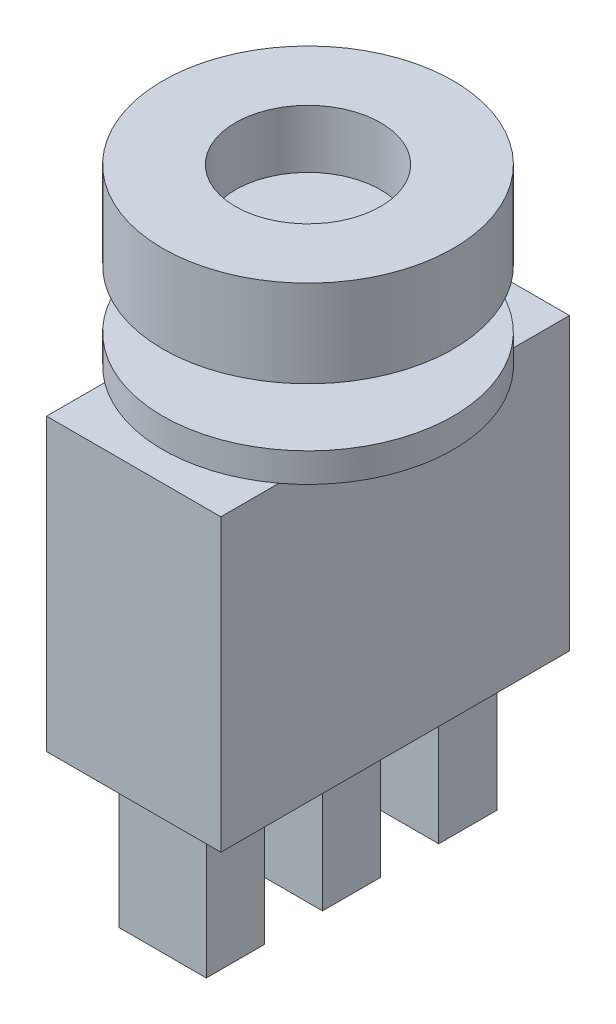
from build123d import *

# Parameters (mm, degrees)
ESQUISSE1_R      = 5
EXTRUSION1_DEPTH = 3
ESQUISSE3_R      = 2
EXTRUSION3_DEPTH = 2
ESQUISSE4_R      = 5
EXTRUSION4_DEPTH = 1
ESQUISSE5_W      = 6
ESQUISSE5_H      = 12
EXTRUSION5_DEPTH = 10
ESQUISSE6_W      = 3
ESQUISSE6_H      = 2
EXTRUSION6_DEPTH = 5
ESQUISSE2_R      = 2.5
EXTRUSION7_DEPTH = 2


with BuildPart() as part:
    # Esquisse1 → Extrusion1 (new body)
    with BuildSketch(Plane(origin=(0, 0, 0), x_dir=(1, 0, 0), z_dir=(0, 1, 0))):
        Circle(ESQUISSE1_R)
    extrude(amount=EXTRUSION1_DEPTH)

    # Esquisse3 → Extrusion3 (add)
    with BuildSketch(Plane.XZ):
        Circle(ESQUISSE3_R)
    extrude(amount=EXTRUSION3_DEPTH)

    # Esquisse4 → Extrusion4 (add)
    with BuildSketch(Plane.XZ.offset(2)):
        Circle(ESQUISSE4_R)
    extrude(amount=EXTRUSION4_DEPTH)

    # Esquisse5 → Extrusion5 (add)
    with BuildSketch(Plane.XZ.offset(3)):
        Rectangle(ESQUISSE5_W, ESQUISSE5_H)
    extrude(amount=EXTRUSION5_DEPTH)

    # Esquisse6 → Extrusion6 (add)
    with BuildSketch(Plane.XZ.offset(13)):
        with Locations((0, 4)):
            Rectangle(ESQUISSE6_W, ESQUISSE6_H)
        Rectangle(ESQUISSE6_W, ESQUISSE6_H)
        with Locations((0, -4)):
            Rectangle(ESQUISSE6_W, ESQUISSE6_H)
    extrude(amount=EXTRUSION6_DEPTH)

    # Esquisse2 → Extrusion7 (cut)
    with BuildSketch(Plane(origin=(0, 3, 0), x_dir=(-1, 0, 0), z_dir=(0, 1, 0))):
        Circle(ESQUISSE2_R)
    extrude(amount=-EXTRUSION7_DEPTH, mode=Mode.SUBTRACT)


solid = part.part
